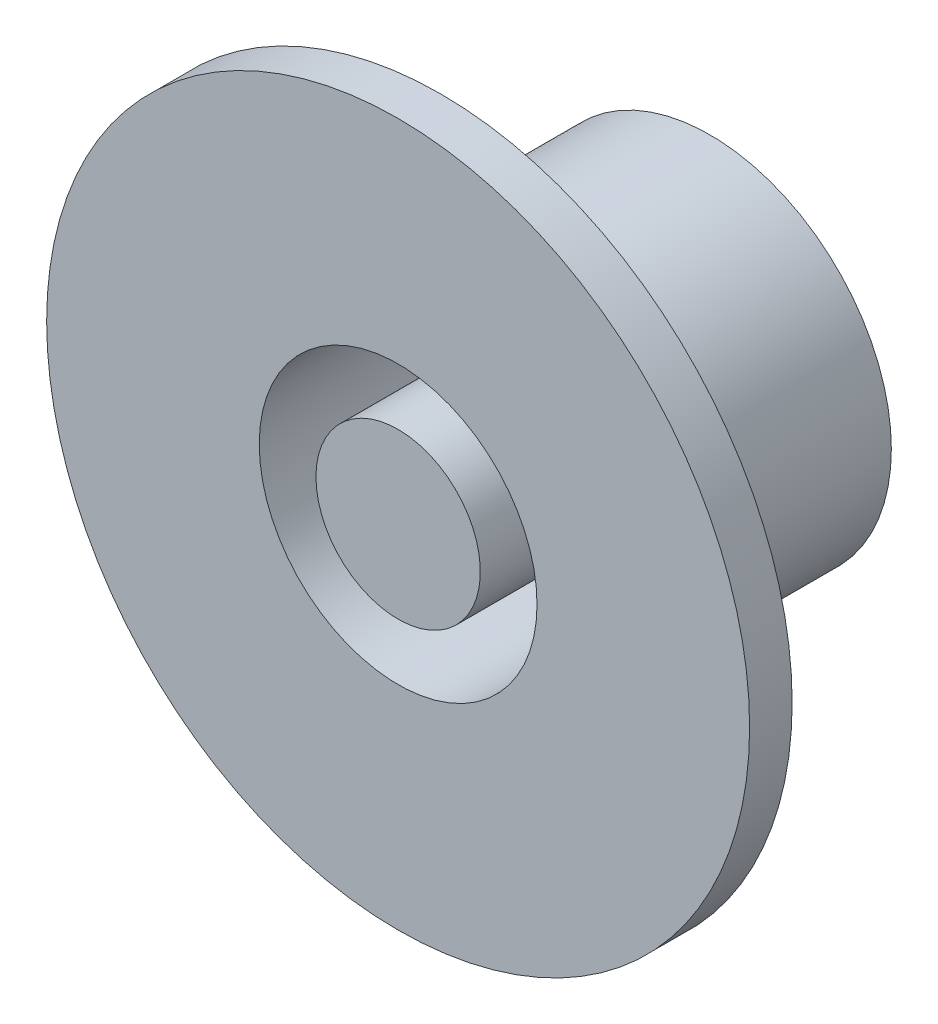
from build123d import *

# Parameters (mm, degrees)
SKETCH4_R          = 1.05
CUT_EXTRUDE1_DEPTH = 4


with BuildPart() as part:
    # Sketch2 → Revolve1 (revolve)
    with BuildSketch(Plane(origin=(0, 0, 0), x_dir=(0, 0, -1), z_dir=(1, 0, 0))):
        Polygon((-22, 0), (-22, 5.8), (-3, 5.8), (-3, 9.8), (-22, 9.8), (-22, 24.8), (-19, 24.8), (-19, 12.8), (0, 12.8), (0, 4), (-19, 4), (-19, 0), align=None)
    revolve(axis=Axis((0, 0, 0), (0, 0, 1)))

    # Sketch4 → Cut-Extrude1 (cut, through all)
    with BuildSketch(Plane.XY.offset(3)):
        with Locations((0, 7.5)):
            Circle(SKETCH4_R)
        with Locations((5.303300859, 5.303300859)):
            Circle(SKETCH4_R)
        with Locations((7.5, 0)):
            Circle(SKETCH4_R)
        with Locations((5.303300859, -5.303300859)):
            Circle(SKETCH4_R)
        with Locations((0, -7.5)):
            Circle(SKETCH4_R)
        with Locations((-5.303300859, -5.303300859)):
            Circle(SKETCH4_R)
        with Locations((-7.5, 0)):
            Circle(SKETCH4_R)
        with Locations((-5.303300859, 5.303300859)):
            Circle(SKETCH4_R)
    extrude(amount=-CUT_EXTRUDE1_DEPTH, mode=Mode.SUBTRACT)


solid = part.part
